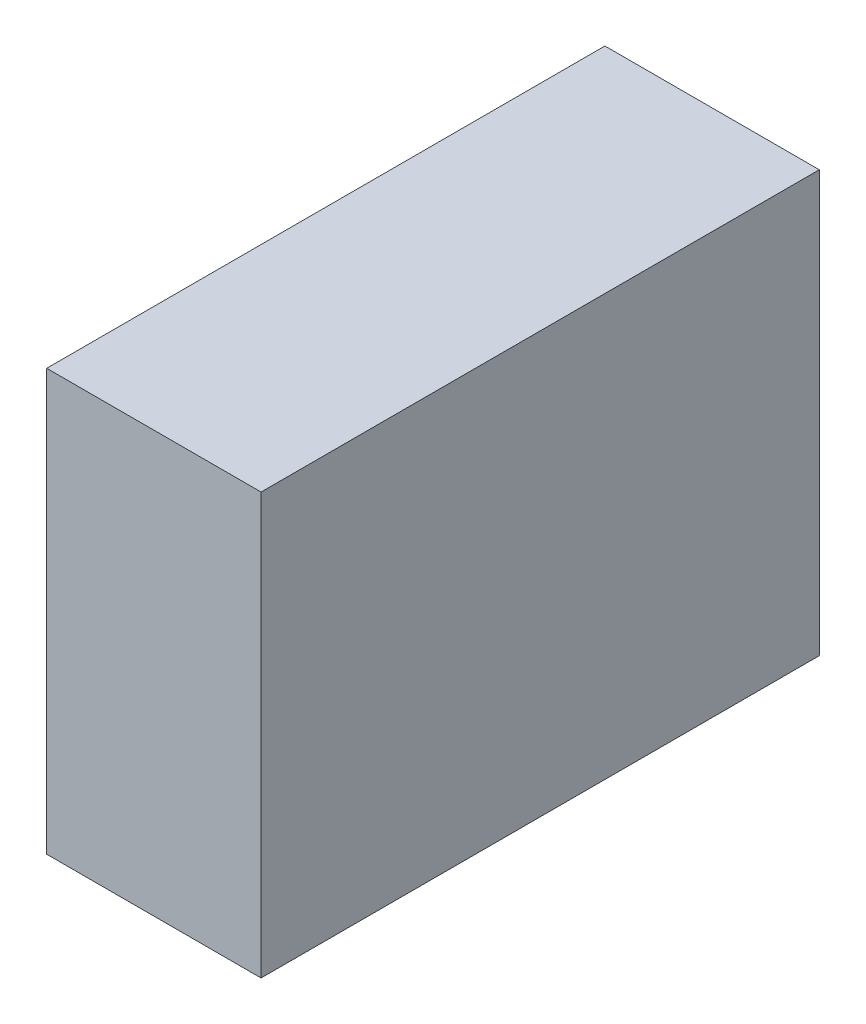
from build123d import *

# Parameters (mm, degrees)
SCHIZZO1_W                   = 9.6
SCHIZZO1_H                   = 18.849
ESTRUSIONE_ESTRUSIONE1_DEPTH = 25


with BuildPart() as part:
    # Schizzo1 → Estrusione-Estrusione1 (new body)
    with BuildSketch(Plane.XY):
        with Locations((4.8, 9.4245)):
            Rectangle(SCHIZZO1_W, SCHIZZO1_H)
    extrude(amount=ESTRUSIONE_ESTRUSIONE1_DEPTH)


solid = part.part
